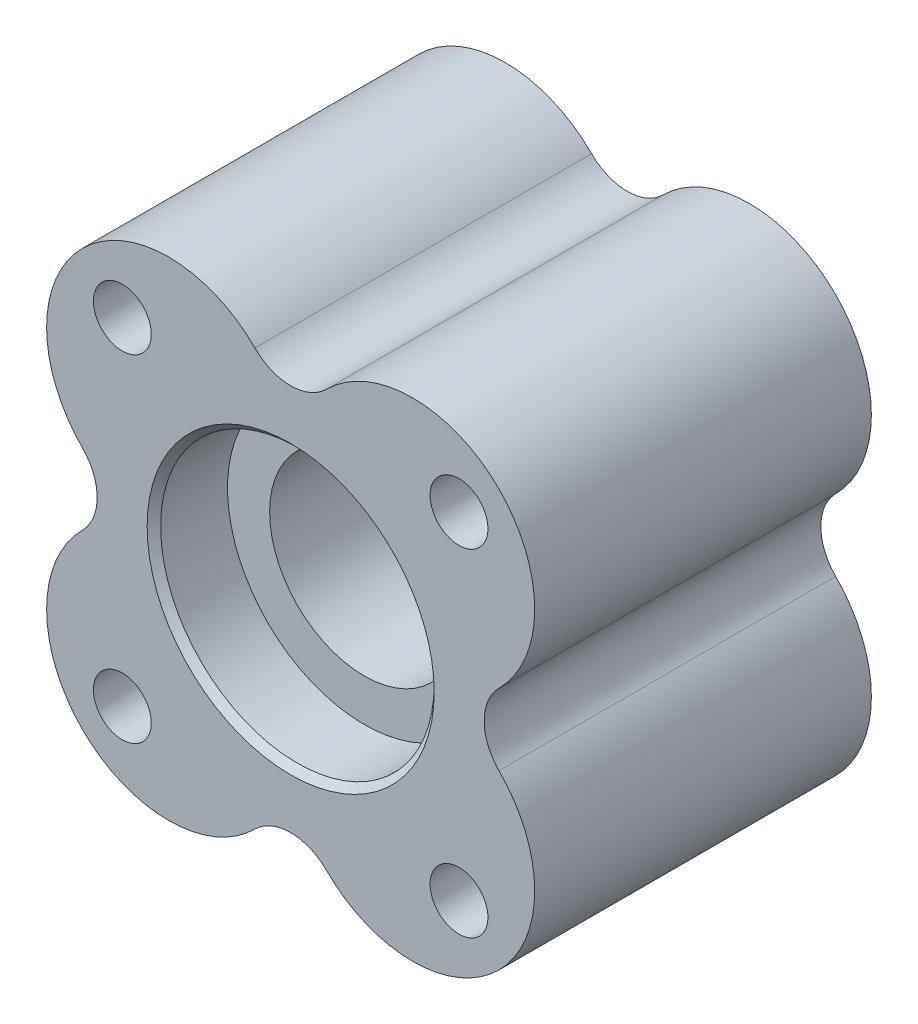
from build123d import *

# Parameters (mm, degrees)
SKETCH1_R                                           = 44.45
SKETCH1_R_2                                         = 3.96875
SKETCH1_R_3                                         = 20.6375
BOSS_EXTRUDE1_DEPTH                                 = 25.4
SKETCH2_R                                           = 20.6375
SKETCH2_R_2                                         = 14.2875
BOSS_EXTRUDE2_DEPTH                                 = 14.2875
SKETCH3_R                                           = 20.6375
SKETCH3_R_2                                         = 14.2875
BOSS_EXTRUDE3_DEPTH                                 = 14.2875
CHAMFER1_SIZE                                       = 1.016
CUT_EXTRUDE1_DEPTH                                  = 50.8
CIRPATTERN1_COUNT                                   = 4
CSK_FOR_5_16_FLAT_HEAD_MACHINE_SCREW_10_D           = 8.72998
CSK_FOR_5_16_FLAT_HEAD_MACHINE_SCREW_10_DEPTH       = 50.8
CSK_FOR_5_16_FLAT_HEAD_MACHINE_SCREW_10_CSINK_D     = 16.129
CSK_FOR_5_16_FLAT_HEAD_MACHINE_SCREW_10_CSINK_ANGLE = 100


with BuildPart() as part:
    # Sketch1 → Boss-Extrude1 (new body, symmetric)
    with BuildSketch(Plane.XY):
        Circle(SKETCH1_R)
        with Locations((-25.4, 25.4)):
            Circle(SKETCH1_R_2, mode=Mode.SUBTRACT)
        with Locations((25.4, 25.4)):
            Circle(SKETCH1_R_2, mode=Mode.SUBTRACT)
        with Locations((25.4, -25.4)):
            Circle(SKETCH1_R_2, mode=Mode.SUBTRACT)
        with Locations((-25.4, -25.4)):
            Circle(SKETCH1_R_2, mode=Mode.SUBTRACT)
        Circle(SKETCH1_R_3, mode=Mode.SUBTRACT)
    extrude(amount=BOSS_EXTRUDE1_DEPTH, both=True)

    # Sketch2 → Boss-Extrude2 (add)
    with BuildSketch(Plane.XY):
        Circle(SKETCH2_R)
        Circle(SKETCH2_R_2, mode=Mode.SUBTRACT)
    extrude(amount=BOSS_EXTRUDE2_DEPTH)

    # Sketch3 → Boss-Extrude3 (add)
    with BuildSketch(Plane(origin=(0, 0, 0), x_dir=(-1, 0, 0), z_dir=(0, 0, -1))):
        with Locations(Location((0, 0, 0), (0, 0, 180))):  # turned: the seam where the file's is
            Circle(SKETCH3_R)
        with Locations(Location((0, 0, 0), (0, 0, 180))):  # turned: the seam where the file's is
            Circle(SKETCH3_R_2, mode=Mode.SUBTRACT)
    extrude(amount=BOSS_EXTRUDE3_DEPTH)

    # Chamfer1
    chamfer1_edges = [part.edges().sort_by_distance(p)[0] for p in [
        (-20.6375, 0, -25.4),
        (-20.6375, 0, 25.4),
    ]]
    chamfer(chamfer1_edges, length=CHAMFER1_SIZE)

    # Sketch4 → Cut-Extrude1 (cut)
    with BuildSketch(Plane(origin=(0, 0, -25.4), x_dir=(-1, 0, 0), z_dir=(0, 0, -1))):
        with BuildLine():
            ThreePointArc((-5.392689271, 31.430896424), (-18.411792847, 36.823585695), (-31.430896424, 31.430896424))
            ThreePointArc((-31.430896424, 31.430896424), (0, 44.45), (31.430896424, 31.430896424))
            ThreePointArc((31.430896424, 31.430896424), (18.411792847, 36.823585695), (5.392689271, 31.430896424))
            ThreePointArc((5.392689271, 31.430896424), (0, 29.19717139), (-5.392689271, 31.430896424))
        make_face()
    cut_extrude1 = extrude(amount=-CUT_EXTRUDE1_DEPTH, mode=Mode.SUBTRACT)

    # CirPattern1: Cut-Extrude1 ×4 about axis
    cirpattern1_axis = Axis((0, 0, 0), (0, 0, 1))
    for i in range(1, CIRPATTERN1_COUNT):
        add(cut_extrude1.rotate(cirpattern1_axis, i * 360 / CIRPATTERN1_COUNT), mode=Mode.SUBTRACT)

    # CSK for 5/16 Flat Head Machine Screw (100)1
    with Locations(Plane(origin=(0, 0, -25.4), x_dir=(-1, 0, 0), z_dir=(0, 0, -1))):
        with Locations((25.4, 25.4), (-25.4, 25.4), (-25.4, -25.4), (25.4, -25.4)):
            CounterSinkHole(CSK_FOR_5_16_FLAT_HEAD_MACHINE_SCREW_10_D / 2, CSK_FOR_5_16_FLAT_HEAD_MACHINE_SCREW_10_CSINK_D / 2, depth=CSK_FOR_5_16_FLAT_HEAD_MACHINE_SCREW_10_DEPTH, counter_sink_angle=CSK_FOR_5_16_FLAT_HEAD_MACHINE_SCREW_10_CSINK_ANGLE)


solid = part.part
